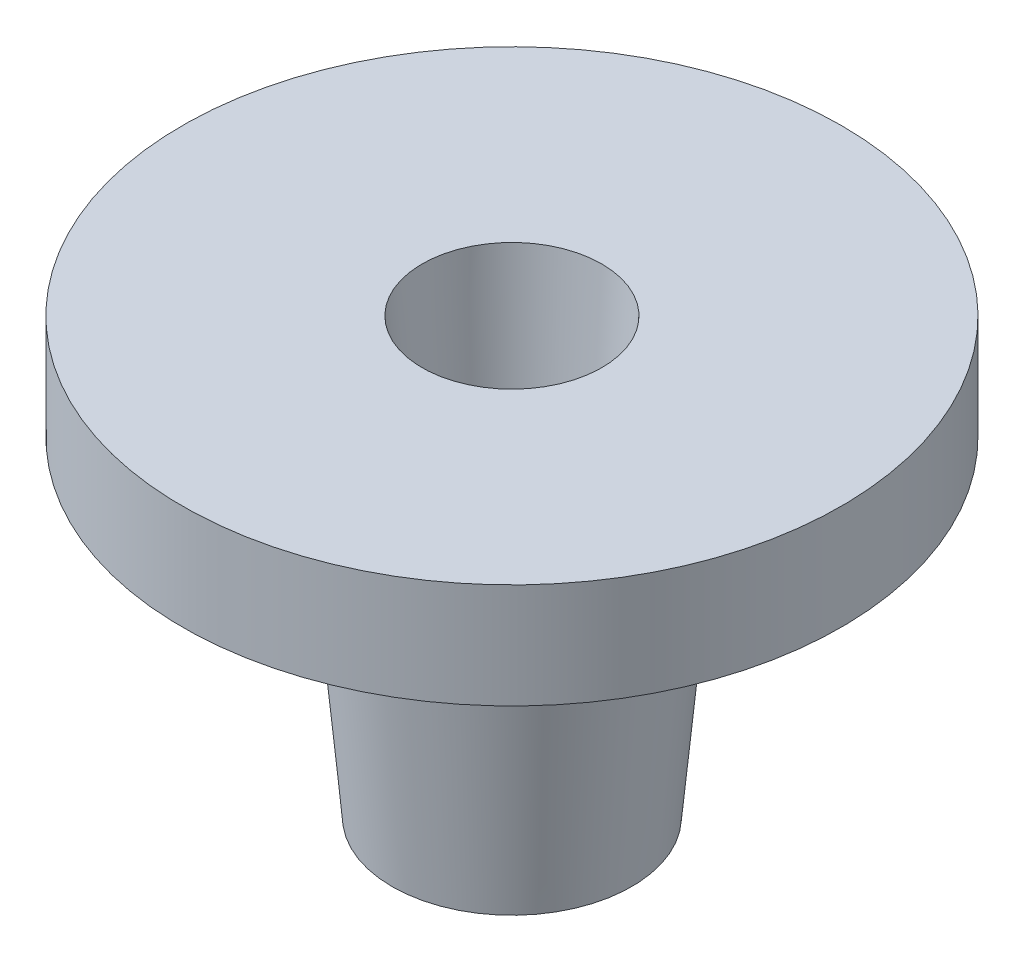
from build123d import *


with BuildPart() as part:
    # Sketch1 → Revolve1 (revolve)
    with BuildSketch(Plane.XY):
        Polygon((-4, 11), (0, 11), (2, 11), (3, 0), (5, 0), (4, 14.5), (-4, 14.5), align=None)
    revolve(axis=Axis((7, 0, 0), (0, 1, 0)))


solid = part.part
